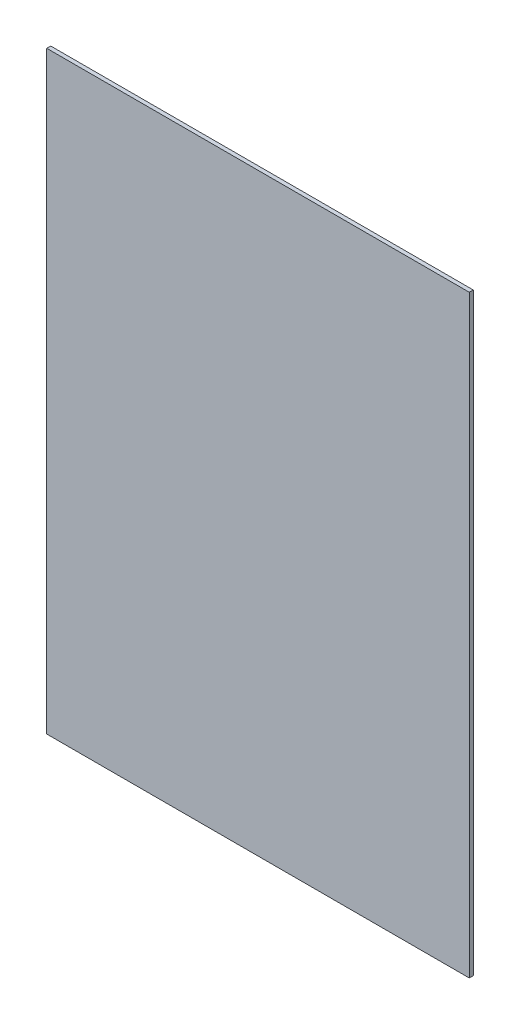
from build123d import *

# Parameters (mm, degrees)
SKETCH1_W           = 539.9532
SKETCH1_H           = 758.9266
BOSS_EXTRUDE1_DEPTH = 5.08


with BuildPart() as part:
    # Sketch1 → Boss-Extrude1 (new body)
    with BuildSketch(Plane.XY):
        with Locations((269.9766, 379.4633)):
            Rectangle(SKETCH1_W, SKETCH1_H)
    extrude(amount=BOSS_EXTRUDE1_DEPTH)


solid = part.part
